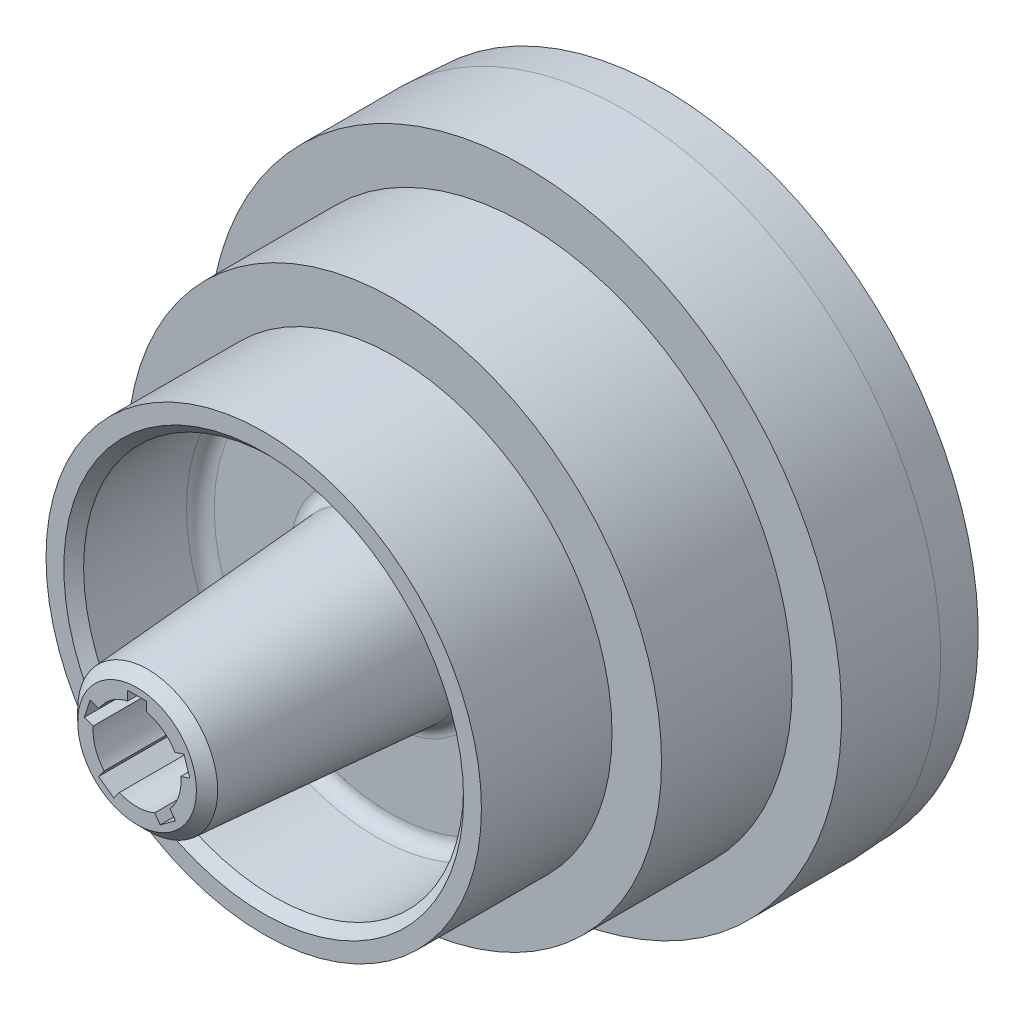
from build123d import *

# Parameters (mm, degrees)
CHAMFER1_SIZE2        = 2.695714625
CHAMFER1_SIZE         = 2.5
CHAMFER1_EDGE_2_SIZE  = 2.5
CHAMFER1_EDGE_3_SIZE  = 2.5
CHAMFER1_EDGE_4_SIZE2 = 2.937714297
CHAMFER1_EDGE_4_SIZE  = 2.5
FILLET1_R             = 3.5
CUT_EXTRUDE1_DEPTH    = 45
CIRPATTERN1_COUNT     = 5


with BuildPart() as part:
    # Sketch1 → Revolve3 (revolve)
    with BuildSketch(Plane(origin=(0, 0, 0), x_dir=(1, 0, 0), z_dir=(0, 1, 0))):
        Polygon((-11.11, 105), (-11.11, 0), (-17.5, 0), (-22, 64), (-48, 64), (-48, 32), (-55, 32), (-55, 65), (-67.5, 65), (-67.5, 98), (-80, 98), (-80, 123), (-79.5, 133), (-74, 133), (-74, 106), (-61, 106), (-61, 73), (-22, 73), (-17.5, 105), align=None)
    revolve(axis=Axis((0, 0, -121.217391304), (0, 0, 1)))

    # Chamfer1
    chamfer1_edges = [part.edges().sort_by_distance(p)[0] for p in [
        (17.5, 0, 0),
    ]]
    chamfer(chamfer1_edges, length=CHAMFER1_SIZE, length2=CHAMFER1_SIZE2)

    # Chamfer1 edge 2
    chamfer1_edge_2_edges = [part.edges().sort_by_distance(p)[0] for p in [
        (48, 0, -32),
    ]]
    chamfer(chamfer1_edge_2_edges, length=CHAMFER1_EDGE_2_SIZE)

    # Chamfer1 edge 3
    chamfer1_edge_3_edges = [part.edges().sort_by_distance(p)[0] for p in [
        (74, 0, -133),
    ]]
    chamfer(chamfer1_edge_3_edges, length=CHAMFER1_EDGE_3_SIZE)

    # Chamfer1 edge 4
    chamfer1_edge_4_edges = [part.edges().sort_by_distance(p)[0] for p in [
        (17.5, 0, -105),
    ]]
    chamfer(chamfer1_edge_4_edges, length=CHAMFER1_EDGE_4_SIZE, length2=CHAMFER1_EDGE_4_SIZE2)

    # Fillet1
    fillet1_edges = [part.edges().sort_by_distance(p)[0] for p in [
        (22, 0, -64),
        (48, 0, -64),
        (74, 0, -106),
        (61, 0, -106),
        (61, 0, -73),
        (22, 0, -73),
    ]]
    fillet(fillet1_edges, radius=FILLET1_R)

    # Sketch2 → Cut-Extrude1 (cut)
    with BuildSketch(Plane.XY):
        with BuildLine():
            Line((-2.38, 10.852082749), (-2.38, 13.232082749))
            Line((-2.38, 13.232082749), (2.38, 13.232082749))
            Line((2.38, 13.232082749), (2.38, 10.852082749))
            ThreePointArc((2.38, 10.852082749), (0, -11.11), (-2.38, 10.852082749))
        make_face()
    cut_extrude1 = extrude(amount=-CUT_EXTRUDE1_DEPTH, mode=Mode.SUBTRACT)

    # CirPattern1: Cut-Extrude1 ×5 about axis
    cirpattern1_axis = Axis((0, 0, 0), (0, 0, 1))
    for i in range(1, CIRPATTERN1_COUNT):
        add(cut_extrude1.rotate(cirpattern1_axis, i * 360 / CIRPATTERN1_COUNT), mode=Mode.SUBTRACT)


solid = part.part
